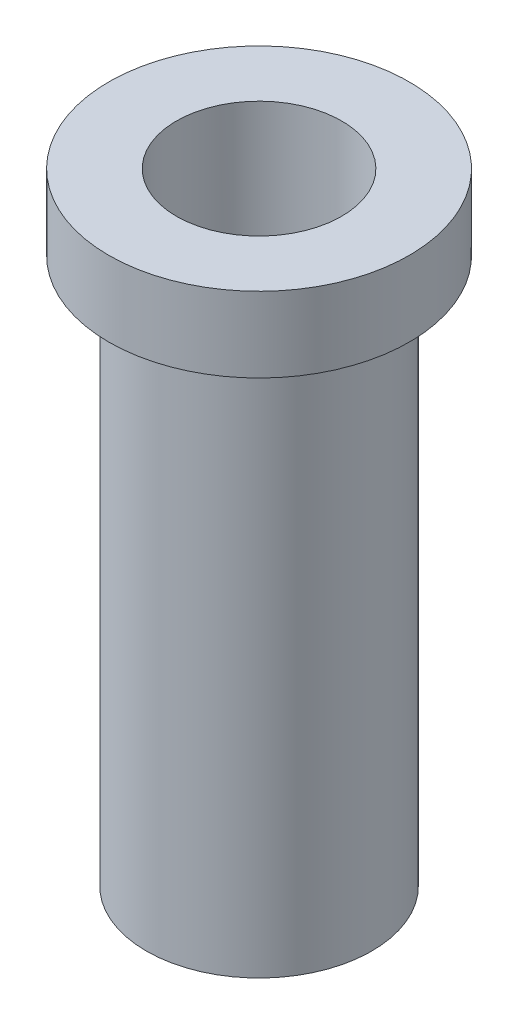
from build123d import *

# Parameters (mm, degrees)
SKETCH2_R          = 5.5
CUT_EXTRUDE1_DEPTH = 45


with BuildPart() as part:
    # Sketch1 → Revolve1 (revolve)
    with BuildSketch(Plane.XY):
        Polygon((0, 0), (0, 36.351403058), (-2.5, 36.351403058), (-2.5, 41.351403058), (7.5, 41.351403058), (7.5, 0), align=None)
    revolve(axis=Axis((7.5, 41.351403058, 0), (0, -1, 0)))

    # Sketch2 → Cut-Extrude1 (cut)
    with BuildSketch(Plane(origin=(0, 41.351403058, 0), x_dir=(1, 0, 0), z_dir=(0, 1, 0))):
        with Locations((7.5, 0)):
            Circle(SKETCH2_R)
    extrude(amount=-CUT_EXTRUDE1_DEPTH, mode=Mode.SUBTRACT)


solid = part.part
